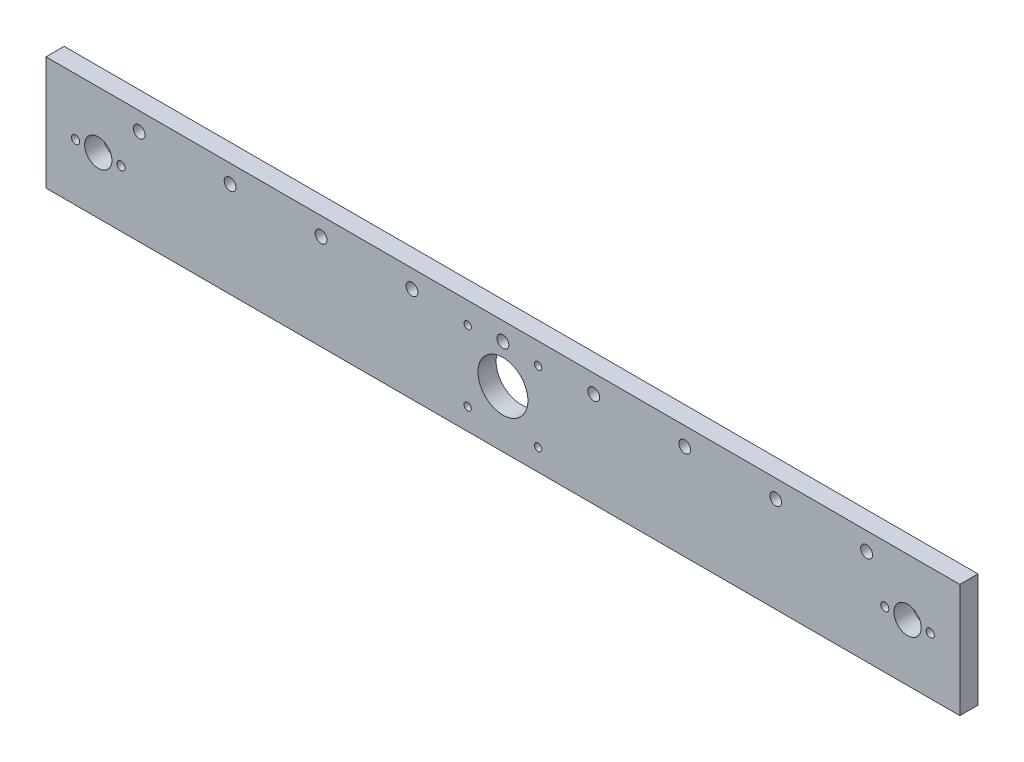
from build123d import *

# Parameters (mm, degrees)
SKETCH1_W           = 402
SKETCH1_H           = 50
SKETCH1_R           = 6
SKETCH1_R_2         = 1.8
SKETCH1_R_3         = 11
SKETCH1_R_4         = 1.6
SKETCH1_R_5         = 2.6
BOSS_EXTRUDE1_DEPTH = 8


with BuildPart() as part:
    # Sketch1 → Boss-Extrude1 (new body)
    with BuildSketch(Plane.XY):
        Rectangle(SKETCH1_W, SKETCH1_H)
        with Locations((-178, 0)):
            Circle(SKETCH1_R, mode=Mode.SUBTRACT)
        with Locations((168, 0)):
            Circle(SKETCH1_R_2, mode=Mode.SUBTRACT)
        Circle(SKETCH1_R_3, mode=Mode.SUBTRACT)
        with Locations((-188, 0)):
            Circle(SKETCH1_R_2, mode=Mode.SUBTRACT)
        with Locations((-168, 0)):
            Circle(SKETCH1_R_2, mode=Mode.SUBTRACT)
        with Locations((188, 0)):
            Circle(SKETCH1_R_2, mode=Mode.SUBTRACT)
        with Locations((178, 0)):
            Circle(SKETCH1_R, mode=Mode.SUBTRACT)
        with Locations((-15.5, 15.5)):
            Circle(SKETCH1_R_4, mode=Mode.SUBTRACT)
        with Locations((15.5, 15.5)):
            Circle(SKETCH1_R_4, mode=Mode.SUBTRACT)
        with Locations((-15.5, -15.5)):
            Circle(SKETCH1_R_4, mode=Mode.SUBTRACT)
        with Locations((15.5, -15.5)):
            Circle(SKETCH1_R_4, mode=Mode.SUBTRACT)
        with Locations((0, 17)):
            Circle(SKETCH1_R_5, mode=Mode.SUBTRACT)
        with Locations((40, 17)):
            Circle(SKETCH1_R_5, mode=Mode.SUBTRACT)
        with Locations((80, 17)):
            Circle(SKETCH1_R_5, mode=Mode.SUBTRACT)
        with Locations((120, 17)):
            Circle(SKETCH1_R_5, mode=Mode.SUBTRACT)
        with Locations((160, 17)):
            Circle(SKETCH1_R_5, mode=Mode.SUBTRACT)
        with Locations((-40, 17)):
            Circle(SKETCH1_R_5, mode=Mode.SUBTRACT)
        with Locations((-80, 17)):
            Circle(SKETCH1_R_5, mode=Mode.SUBTRACT)
        with Locations((-120, 17)):
            Circle(SKETCH1_R_5, mode=Mode.SUBTRACT)
        with Locations((-160, 17)):
            Circle(SKETCH1_R_5, mode=Mode.SUBTRACT)
    extrude(amount=BOSS_EXTRUDE1_DEPTH)


solid = part.part
